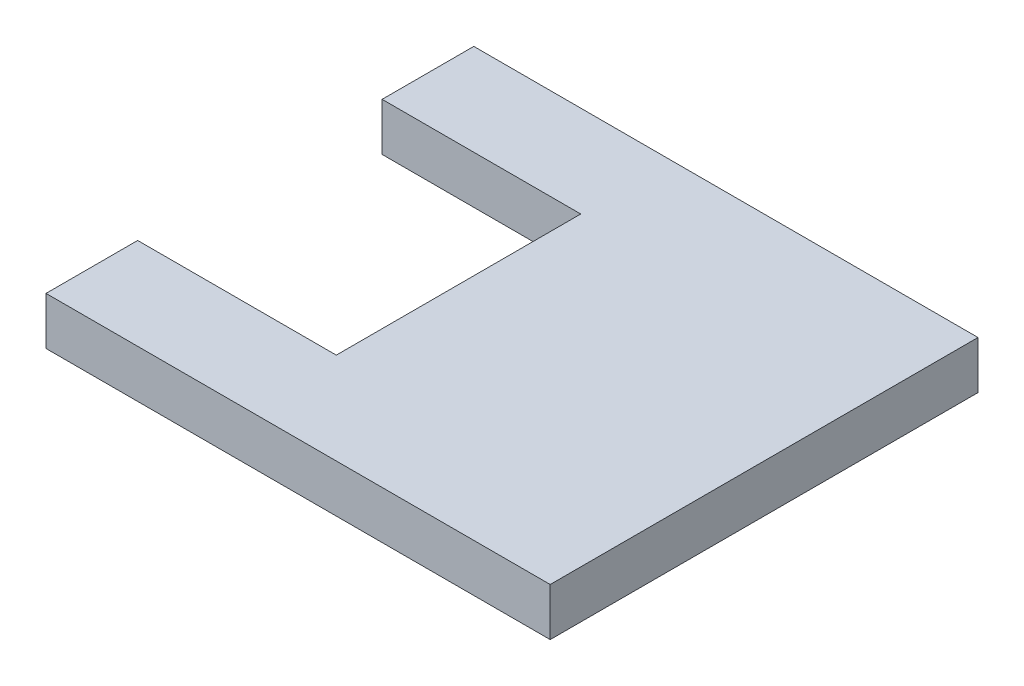
from build123d import *

# Parameters (mm, degrees)
BOSS_EXTRUDE1_DEPTH = 79.375


with BuildPart() as part:
    # Sketch2 → Boss-Extrude1 (new body)
    with BuildSketch(Plane(origin=(0, 0, 0), x_dir=(1, 0, 0), z_dir=(0, 1, 0))):
        Polygon((-514.157575758, -952.434268404), (-514.157575758, -800.034268404), (324.042424242, -800.034268404), (324.042424242, -1511.234268404), (-514.157575758, -1511.234268404), (-514.157575758, -1358.834268404), (-183.957575758, -1358.834268404), (-183.957575758, -952.434268404), align=None)
    extrude(amount=-BOSS_EXTRUDE1_DEPTH)


solid = part.part
